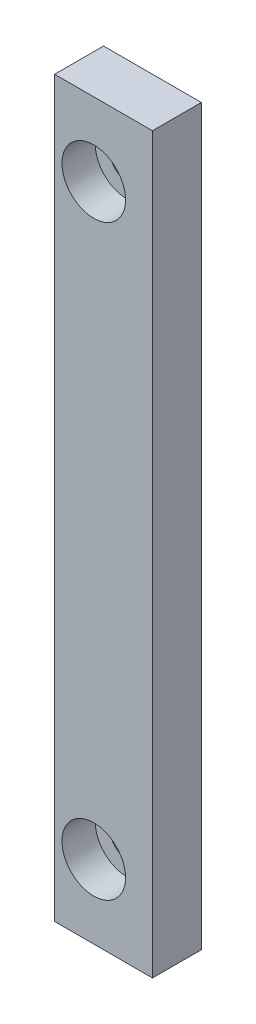
from build123d import *

# Parameters (mm, degrees)
SKETCH_1_W                   = 10
SKETCH_1_H                   = 75
EXTRUDE_1_DEPTH              = 5
HOLE_WIZARD_M3_1_D           = 3.4
HOLE_WIZARD_M3_1_DEPTH       = 10.1
HOLE_WIZARD_M3_1_CBORE_D     = 6.5
HOLE_WIZARD_M3_1_CBORE_DEPTH = 3.4
HOLE_WIZARD_M3_1_TIP         = 1.021463052


with BuildPart() as part:
    # 草图1 → 凸台-拉伸1 (new body)
    with BuildSketch(Plane.XY):
        with Locations((5, 37.5)):
            Rectangle(SKETCH_1_W, SKETCH_1_H)
    extrude(amount=EXTRUDE_1_DEPTH)

    # M3 六角凹头螺钉的柱形沉头孔1
    with Locations(Plane.XY.offset(5)):
        with Locations((4, 67.5), (4, 7.5)):
            CounterBoreHole(HOLE_WIZARD_M3_1_D / 2, HOLE_WIZARD_M3_1_CBORE_D / 2, HOLE_WIZARD_M3_1_CBORE_DEPTH, depth=HOLE_WIZARD_M3_1_DEPTH)
            with Locations((0, 0, -(HOLE_WIZARD_M3_1_DEPTH + HOLE_WIZARD_M3_1_TIP / 2))):  # 118° drill point
                Cone(0, HOLE_WIZARD_M3_1_D / 2, HOLE_WIZARD_M3_1_TIP, mode=Mode.SUBTRACT)


solid = part.part
